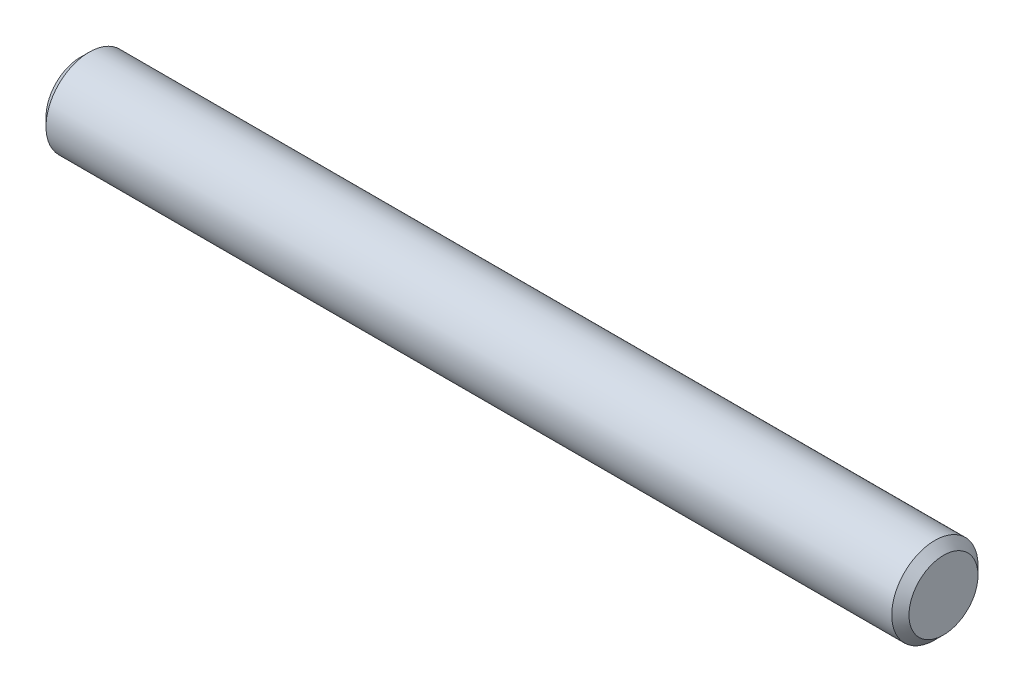
from build123d import *

# Parameters (mm, degrees)
SKETCH2_R           = 3.175
EXTRUDE1_DEPTH      = 31.75
EXTRUDE1_DEPTH_BACK = 31.75
CHAMFER1_SIZE       = 0.635


with BuildPart() as part:
    # Sketch2 → Extrude1 (new body, two sides)
    with BuildSketch(Plane(origin=(0, 0, 0), x_dir=(0, 0, -1), z_dir=(1, 0, 0))) as extrude1_sk:
        Circle(SKETCH2_R)
    extrude(amount=EXTRUDE1_DEPTH)
    extrude(extrude1_sk.sketch, amount=-EXTRUDE1_DEPTH_BACK)

    # Chamfer1
    chamfer1_edges = [part.edges().sort_by_distance(p)[0] for p in [
        (-31.75, 0, 3.175),
        (31.75, 0, 3.175),
    ]]
    chamfer(chamfer1_edges, length=CHAMFER1_SIZE)


solid = part.part
